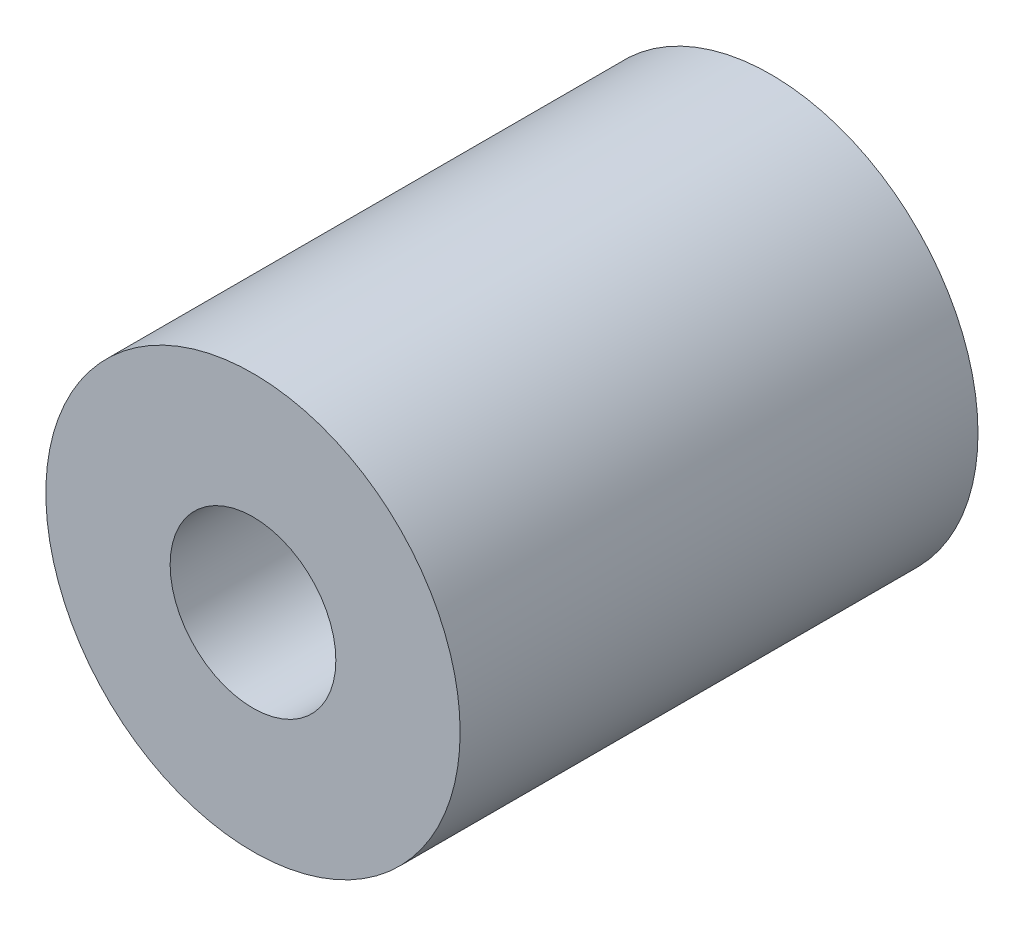
from build123d import *

# Parameters (mm, degrees)
SKETCH1_R           = 4
SKETCH1_R_2         = 1.6
EXTRUDE1_DEPTH      = 5
EXTRUDE1_DEPTH_BACK = 5


with BuildPart() as part:
    # Sketch1 → Extrude1 (new body, two sides)
    with BuildSketch(Plane.XY) as extrude1_sk:
        Circle(SKETCH1_R)
        Circle(SKETCH1_R_2, mode=Mode.SUBTRACT)
    extrude(amount=EXTRUDE1_DEPTH)
    extrude(extrude1_sk.sketch, amount=-EXTRUDE1_DEPTH_BACK)


solid = part.part
